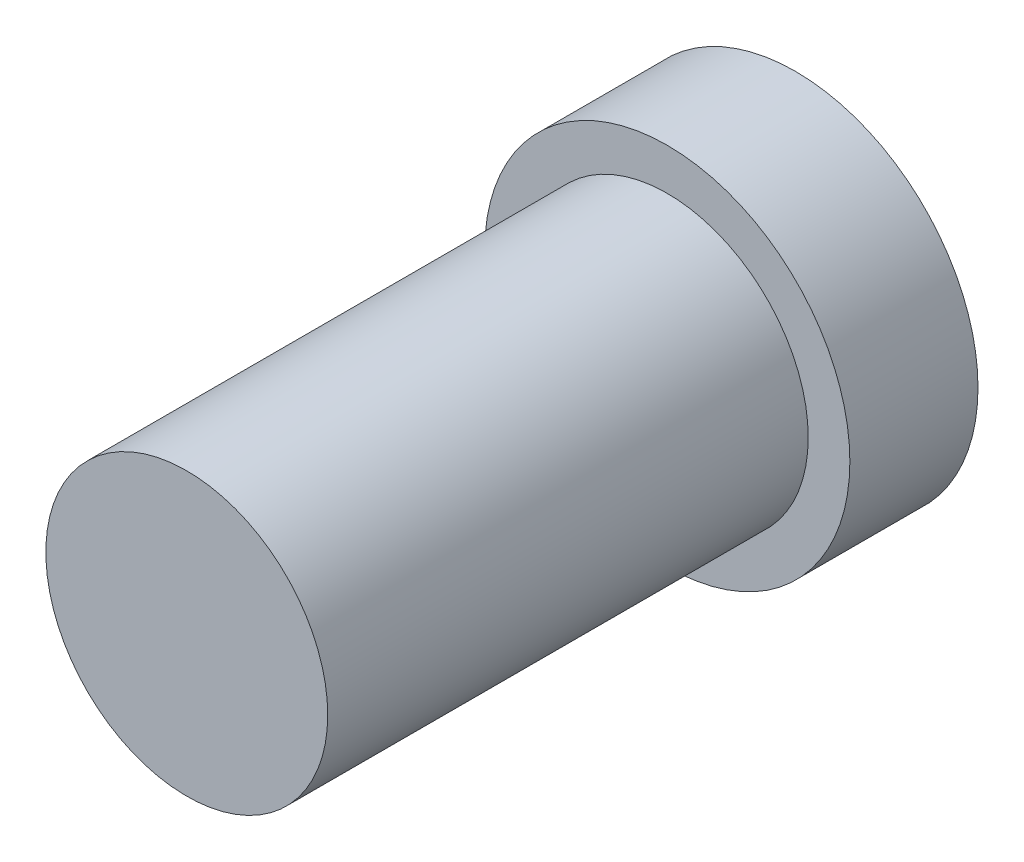
from build123d import *


with BuildPart() as part:
    # Sketch1 → Revolve1 (revolve)
    with BuildSketch(Plane(origin=(0, 0, 0), x_dir=(1, 0, 0), z_dir=(0, 1, 0)), mode=Mode.PRIVATE) as revolve1_sk:
        Polygon((0, 0), (-22, 0), (-22, 75), (-28.5, 75), (-28.5, 95), (0, 95), align=None)
    revolve(revolve1_sk.sketch.rotate(Axis((0, 0, 0), (0, 0, -1)), 180), axis=Axis((0, 0, 0), (0, 0, -1)))  # turned: the seam where the file's is


solid = part.part
